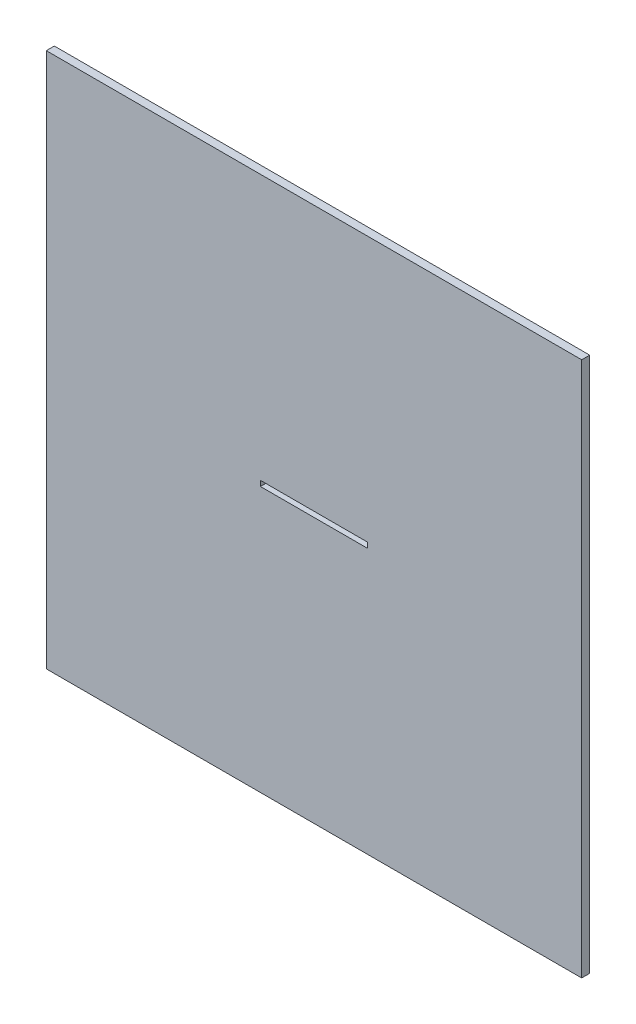
from build123d import *

# Parameters (mm, degrees)
ESBO_O1_W                = 1000
ESBO_O1_H                = 1000
RESSALTO_EXTRUS_O1_DEPTH = 15
ESBO_O2_W                = 200
ESBO_O2_H                = 10
CORTE_EXTRUS_O1_DEPTH    = 16


with BuildPart() as part:
    # Esboço1 → Ressalto-extrusão1 (new body)
    with BuildSketch(Plane.XY):
        Rectangle(ESBO_O1_W, ESBO_O1_H)
    extrude(amount=RESSALTO_EXTRUS_O1_DEPTH)

    # Esboço2 → Corte-extrusão1 (cut, through all)
    with BuildSketch(Plane.XY.offset(15)):
        Rectangle(ESBO_O2_W, ESBO_O2_H)
    extrude(amount=-CORTE_EXTRUS_O1_DEPTH, mode=Mode.SUBTRACT)


solid = part.part
